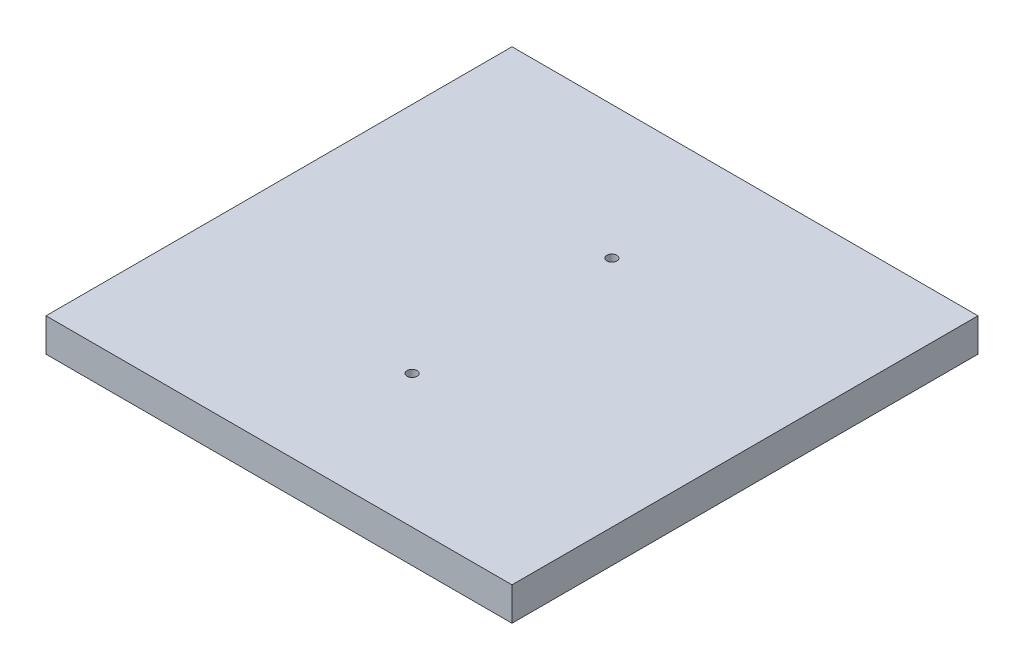
from build123d import *

# Parameters (mm, degrees)
SKETCH1_W           = 70
SKETCH1_H           = 70
BOSS_EXTRUDE1_DEPTH = 5
SKETCH7_R           = 0.75
CUT_EXTRUDE1_DEPTH  = 6


with BuildPart() as part:
    # Sketch1 → Boss-Extrude1 (new body)
    with BuildSketch(Plane(origin=(0, 0, 0), x_dir=(1, 0, 0), z_dir=(0, 1, 0))):
        Rectangle(SKETCH1_W, SKETCH1_H)
    extrude(amount=-BOSS_EXTRUDE1_DEPTH)

    # Sketch7 → Cut-Extrude1 (cut, through all)
    with BuildSketch(Plane(origin=(0, 0, 0), x_dir=(1, 0, 0), z_dir=(0, 1, 0))):
        with Locations((0, 15)):
            Circle(SKETCH7_R)
        with Locations((0, -15)):
            Circle(SKETCH7_R)
    extrude(amount=-CUT_EXTRUDE1_DEPTH, mode=Mode.SUBTRACT)


solid = part.part
